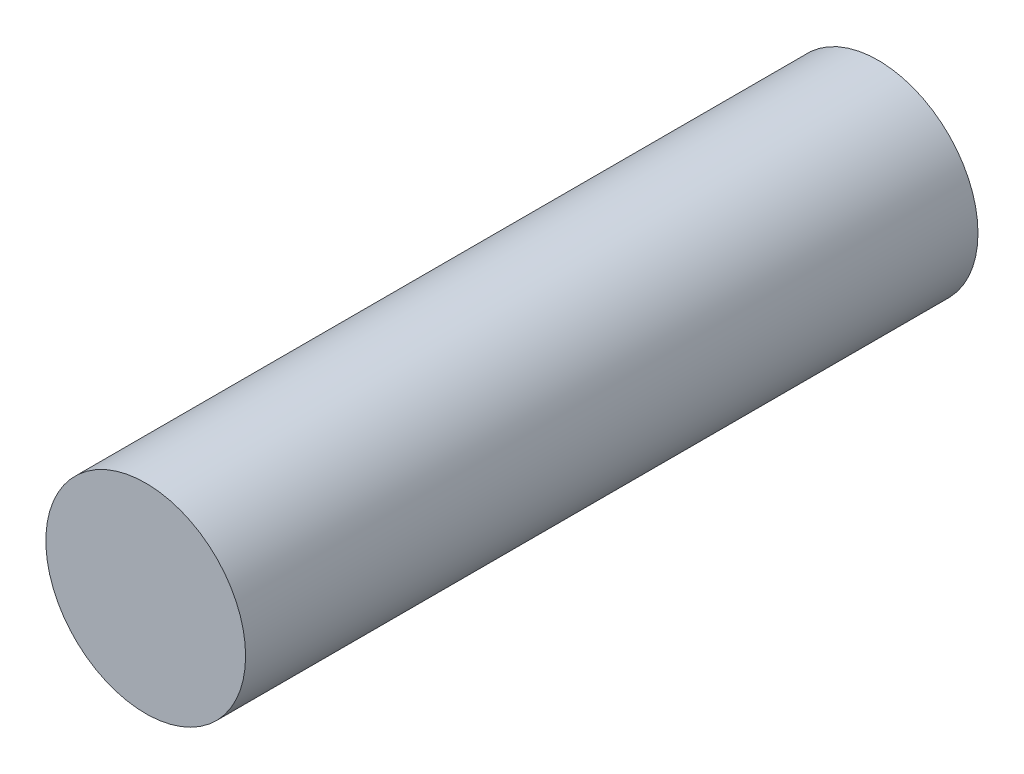
from build123d import *

# Parameters (mm, degrees)
SKETCH1_R           = 15
BOSS_EXTRUDE1_DEPTH = 110


with BuildPart() as part:
    # Sketch1 → Boss-Extrude1 (new body)
    with BuildSketch(Plane.XY):
        Circle(SKETCH1_R)
    extrude(amount=BOSS_EXTRUDE1_DEPTH)


solid = part.part
